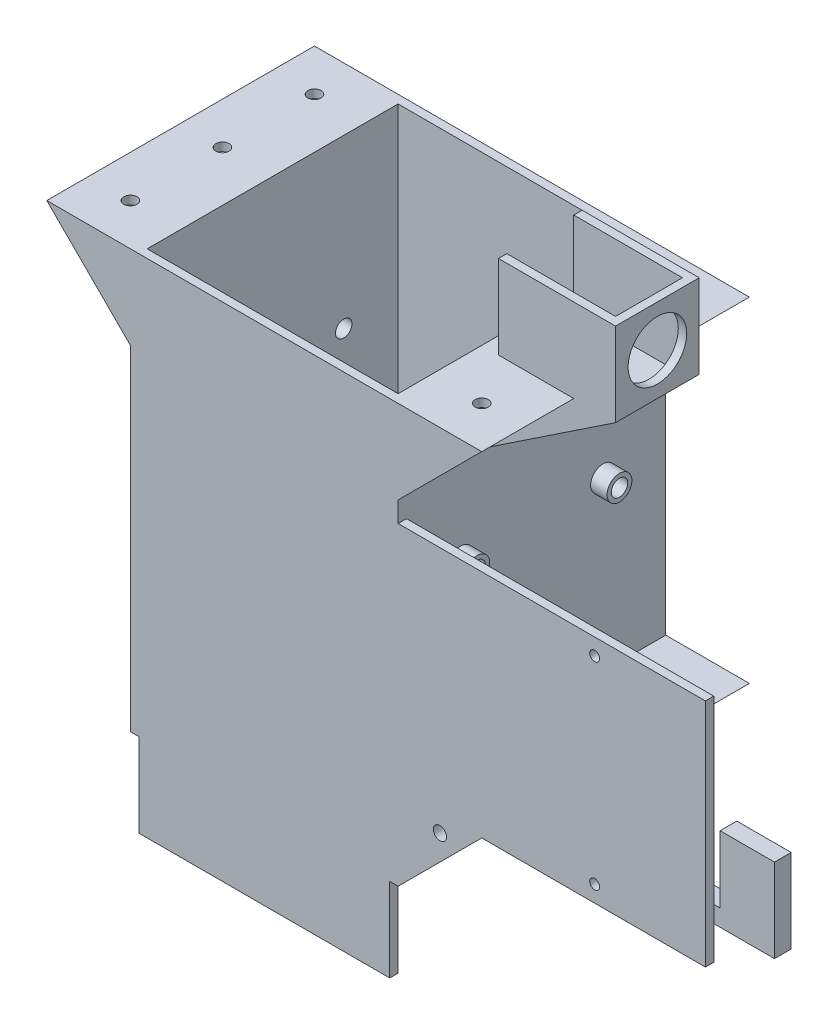
from build123d import *

# Parameters (mm, degrees)
SKETCH1_W            = 81.28
SKETCH1_H            = 81.28
SKETCH1_W_2          = 76.2
SKETCH1_H_2          = 76.2
BOSS_EXTRUDE1_DEPTH  = 177.8
SKETCH2_W            = 2.54
SKETCH2_H            = 38.1
BOSS_EXTRUDE2_DEPTH  = 25.4
SKETCH3_W            = 2.54
SKETCH3_H            = 25.4
CUT_EXTRUDE1_DEPTH   = 212.720846399
BOSS_EXTRUDE3_DEPTH  = 12.7
BOSS_EXTRUDE4_DEPTH  = 12.7
SKETCH14_W           = 5.08
SKETCH14_H           = 25.4
BOSS_EXTRUDE6_DEPTH  = 76.2
CUT_EXTRUDE2_REACH   = 243.407
SKETCH16_W           = 24.13
SKETCH16_H           = 20.32
SKETCH22_R           = 2
CUT_EXTRUDE6_DEPTH   = 252.036309724
SKETCH28_W           = 25.4
SKETCH28_H           = 50.8
BOSS_EXTRUDE7_DEPTH  = 38.1
CUT_EXTRUDE8_REACH   = 245.43
SKETCH32_W           = 33.02
SKETCH32_H           = 20.32
CUT_EXTRUDE9_DEPTH   = 25.4
CUT_EXTRUDE13_REACH  = 245.27
SKETCH34_R           = 8.89
BOSS_EXTRUDE9_DEPTH  = 2.54
SKETCH38_W           = 2.54
SKETCH38_H           = 25.4
CUT_EXTRUDE15_DEPTH  = 63.5
CUT_EXTRUDE17_REACH  = 224.71
SKETCH40_R           = 2.5
SKETCH41_R           = 3.77
SKETCH41_R_2         = 2.5
BOSS_EXTRUDE10_DEPTH = 5
SKETCH42_R           = 3.77
SKETCH42_R_2         = 2.5
BOSS_EXTRUDE11_DEPTH = 5
SKETCH43_W           = 76.2
SKETCH43_H           = 76.2
CUT_EXTRUDE20_DEPTH  = 25.4
SKETCH44_W           = 174.6
SKETCH44_H           = 70
SKETCH44_R           = 1.5
BOSS_EXTRUDE12_DEPTH = 2.54
BOSS_EXTRUDE13_DEPTH = 2.54
BOSS_EXTRUDE14_DEPTH = 2.54
BOSS_EXTRUDE15_REACH = 264.115
BOSS_EXTRUDE16_DEPTH = 2.54
BOSS_EXTRUDE17_DEPTH = 2.54
BOSS_EXTRUDE18_REACH = 264.115
SKETCH51_R           = 2
CUT_EXTRUDE21_DEPTH  = 2.54


with BuildPart() as part:
    # Sketch1 → Boss-Extrude1 (new body)
    with BuildSketch(Plane(origin=(0, 0, 0), x_dir=(1, 0, 0), z_dir=(0, 1, 0))):
        with Locations((40.64, 40.64)):
            Rectangle(SKETCH1_W, SKETCH1_H)
        with Locations((40.64, 40.64)):
            Rectangle(SKETCH1_W_2, SKETCH1_H_2, mode=Mode.SUBTRACT)
    extrude(amount=BOSS_EXTRUDE1_DEPTH)

    # Sketch2 → Boss-Extrude2 (add)
    with BuildSketch(Plane(origin=(0, 0, 0), x_dir=(0, 0, -1), z_dir=(1, 0, 0))):
        with Locations((64.77, 19.05)):
            Rectangle(SKETCH2_W, SKETCH2_H)
    extrude(amount=-BOSS_EXTRUDE2_DEPTH)

    # Sketch3 → Cut-Extrude1 (cut, through all)
    with BuildSketch(Plane.XY):
        with Locations((80.01, 12.7)):
            Rectangle(SKETCH3_W, SKETCH3_H)
    extrude(amount=-CUT_EXTRUDE1_DEPTH, mode=Mode.SUBTRACT)

    # Sketch7 → Boss-Extrude3 (add)
    with BuildSketch(Plane.XY):
        Polygon((81.28, 25.4), (106.68, 50.8), (81.28, 50.8), align=None)
    extrude(amount=-BOSS_EXTRUDE3_DEPTH)

    # Sketch10 → Boss-Extrude4 (add)
    with BuildSketch(Plane(origin=(0, 0, -81.28), x_dir=(-1, 0, 0), z_dir=(0, 0, -1))):
        Polygon((-81.28, 25.4), (-81.28, 50.8), (-106.68, 50.8), align=None)
    extrude(amount=-BOSS_EXTRUDE4_DEPTH)

    # Sketch14 → Boss-Extrude6 (add)
    with BuildSketch(Plane(origin=(81.28, 0, 0), x_dir=(0, 0, -1), z_dir=(1, 0, 0))):
        with Locations((40.64, 38.1)):
            Rectangle(SKETCH14_W, SKETCH14_H)
    extrude(amount=BOSS_EXTRUDE6_DEPTH)

    # Sketch16 → Cut-Extrude2 (cut, up to next)
    with BuildSketch(Plane.XY.offset(-38.1), mode=Mode.PRIVATE) as cut_extrude2_sk1:
        with Locations((128.905, 40.64)):
            Rectangle(SKETCH16_W, SKETCH16_H)
    cut_extrude2_tool1 = extrude(cut_extrude2_sk1.sketch, amount=-CUT_EXTRUDE2_REACH, mode=Mode.PRIVATE) & part.part
    add(cut_extrude2_tool1.solids().sort_by_distance((128.905, 40.64, -38.1))[0], mode=Mode.SUBTRACT)

    # Sketch22 → Cut-Extrude6 (cut, through all)
    with BuildSketch(Plane.XY):
        with Locations((93.98, 45.72)):
            Circle(SKETCH22_R)
    extrude(amount=-CUT_EXTRUDE6_DEPTH, mode=Mode.SUBTRACT)

    # Sketch28 → Boss-Extrude7 (add)
    with BuildSketch(Plane(origin=(81.28, 0, 0), x_dir=(0, 0, -1), z_dir=(1, 0, 0))):
        with Locations((40.64, 152.4)):
            Rectangle(SKETCH28_W, SKETCH28_H)
    extrude(amount=BOSS_EXTRUDE7_DEPTH)

    # Sketch30 → Cut-Extrude8 (cut, up to next)
    with BuildSketch(Plane.XY.offset(-27.94), mode=Mode.PRIVATE) as cut_extrude8_sk1:
        Polygon((81.28, 127), (119.38, 127), (119.38, 152.4), align=None)
    cut_extrude8_tool1 = extrude(cut_extrude8_sk1.sketch, amount=-CUT_EXTRUDE8_REACH, mode=Mode.PRIVATE) & part.part
    add(cut_extrude8_tool1.solids().sort_by_distance((106.68, 135.466667, -27.94))[0], mode=Mode.SUBTRACT)

    # Sketch32 → Cut-Extrude9 (cut)
    with BuildSketch(Plane(origin=(0, 177.8, 0), x_dir=(1, 0, 0), z_dir=(0, 1, 0))):
        with Locations((100.33, 40.64)):
            Rectangle(SKETCH32_W, SKETCH32_H)
    extrude(amount=-CUT_EXTRUDE9_DEPTH, mode=Mode.SUBTRACT)

    # Cut-Extrude13: up to this face of the body (flat: up to its plane)
    cut_extrude13_end = Plane(part.part.faces().sort_by_distance((78.74, 101.6, -40.64))[0])
    # Sketch34 → Cut-Extrude13 (cut, up to the picked face)
    with BuildSketch(Plane(origin=(119.38, 0, 0), x_dir=(0, 0, -1), z_dir=(1, 0, 0)), mode=Mode.PRIVATE) as cut_extrude13_sk1:
        with Locations(Location((40.64, 165.1, 0), (0, 0, 180))):
            Circle(SKETCH34_R)
    cut_extrude13_tool1 = split(extrude(cut_extrude13_sk1.sketch, amount=-CUT_EXTRUDE13_REACH, mode=Mode.PRIVATE), bisect_by=cut_extrude13_end, keep=Keep.BOTH, mode=Mode.PRIVATE)
    add(cut_extrude13_tool1.solids().sort_by(Axis((119.38, 165.1, -40.64), (-1, 0, 0)))[0], mode=Mode.SUBTRACT)

    # Sketch37 → Boss-Extrude9 (add)
    with BuildSketch(Plane.XY.offset(-63.5)):
        Polygon((-25.4, 38.1), (0, 38.1), (0, 52.764696837), align=None)
    extrude(amount=-BOSS_EXTRUDE9_DEPTH)

    # Sketch38 → Cut-Extrude15 (cut)
    with BuildSketch(Plane.XY):
        with Locations((1.27, 12.7)):
            Rectangle(SKETCH38_W, SKETCH38_H)
    extrude(amount=-CUT_EXTRUDE15_DEPTH, mode=Mode.SUBTRACT)

    # Cut-Extrude17: up to this face of the body (flat: up to its plane)
    cut_extrude17_end = Plane(part.part.faces().sort_by_distance((0, 99.23335202, -41.514066738))[0])
    # Sketch40 → Cut-Extrude17 (cut, up to the picked face)
    with BuildSketch(Plane(origin=(81.28, 0, 0), x_dir=(0, 0, -1), z_dir=(1, 0, 0)), mode=Mode.PRIVATE) as cut_extrude17_sk1:
        with Locations((19.05, 101.6)):
            Circle(SKETCH40_R)
    cut_extrude17_tool1 = split(extrude(cut_extrude17_sk1.sketch, amount=-CUT_EXTRUDE17_REACH, mode=Mode.PRIVATE), bisect_by=cut_extrude17_end, keep=Keep.BOTH, mode=Mode.PRIVATE)
    # Sketch40 → Cut-Extrude17 (cut, up to the picked face)
    with BuildSketch(Plane(origin=(81.28, 0, 0), x_dir=(0, 0, -1), z_dir=(1, 0, 0)), mode=Mode.PRIVATE) as cut_extrude17_sk2:
        with Locations((62.23, 101.6)):
            Circle(SKETCH40_R)
    cut_extrude17_tool2 = split(extrude(cut_extrude17_sk2.sketch, amount=-CUT_EXTRUDE17_REACH, mode=Mode.PRIVATE), bisect_by=cut_extrude17_end, keep=Keep.BOTH, mode=Mode.PRIVATE)
    add(cut_extrude17_tool1.solids().sort_by(Axis((81.28, 101.6, -19.05), (-1, 0, 0)))[0], mode=Mode.SUBTRACT)
    add(cut_extrude17_tool2.solids().sort_by(Axis((81.28, 101.6, -62.23), (-1, 0, 0)))[0], mode=Mode.SUBTRACT)

    # Sketch41 → Boss-Extrude10 (add)
    with BuildSketch(Plane(origin=(81.28, 0, 0), x_dir=(0, 0, -1), z_dir=(1, 0, 0))):
        with Locations(Location((19.05, 101.6, 0), (0, 0, 180))):
            Circle(SKETCH41_R)
        with Locations((19.05, 101.6)):
            Circle(SKETCH41_R_2, mode=Mode.SUBTRACT)
        with Locations(Location((62.23, 101.6, 0), (0, 0, 180))):
            Circle(SKETCH41_R)
        with Locations((62.23, 101.6)):
            Circle(SKETCH41_R_2, mode=Mode.SUBTRACT)
    extrude(amount=BOSS_EXTRUDE10_DEPTH)

    # Sketch42 → Boss-Extrude11 (add)
    with BuildSketch(Plane.ZY):
        with Locations((-62.23, 101.6)):
            Circle(SKETCH42_R)
        with Locations(Location((-62.23, 101.6, 0), (0, 0, 180))):
            Circle(SKETCH42_R_2, mode=Mode.SUBTRACT)
        with Locations((-19.05, 101.6)):
            Circle(SKETCH42_R)
        with Locations(Location((-19.05, 101.6, 0), (0, 0, 180))):
            Circle(SKETCH42_R_2, mode=Mode.SUBTRACT)
    extrude(amount=BOSS_EXTRUDE11_DEPTH)

    # Sketch43 → Cut-Extrude20 (cut)
    with BuildSketch(Plane(origin=(0, 177.8, 0), x_dir=(1, 0, 0), z_dir=(0, 1, 0))):
        Polygon((83.82, 53.34), (83.82, 27.94), (81.28, 27.94), (81.28, 0), (0, 0), (0, 81.28), (81.28, 81.28), (81.28, 53.34), align=None)
        with Locations((40.64, 40.64)):
            Rectangle(SKETCH43_W, SKETCH43_H, mode=Mode.SUBTRACT)
    extrude(amount=-CUT_EXTRUDE20_DEPTH, mode=Mode.SUBTRACT)

    # Sketch44 → Boss-Extrude12 (add)
    with BuildSketch(Plane.XY):
        with Locations((87.3, 85.8)):
            Rectangle(SKETCH44_W, SKETCH44_H)
        with Locations((140.97, 115.8)):
            Circle(SKETCH44_R, mode=Mode.SUBTRACT)
        with Locations((140.97, 55.8)):
            Circle(SKETCH44_R, mode=Mode.SUBTRACT)
    extrude(amount=-BOSS_EXTRUDE12_DEPTH)

    # Sketch45 → Boss-Extrude13 (add)
    with BuildSketch(Plane.XY):
        Polygon((0, 152.4), (-25.4, 152.4), (0, 127), align=None)
    extrude(amount=-BOSS_EXTRUDE13_DEPTH)

    # Sketch46 → Boss-Extrude14 (add)
    with BuildSketch(Plane(origin=(0, 0, -81.28), x_dir=(-1, 0, 0), z_dir=(0, 0, -1))):
        Polygon((0, 152.4), (0, 127), (25.4, 152.4), align=None)
    extrude(amount=-BOSS_EXTRUDE14_DEPTH)

    # Sketch47 → Boss-Extrude15 (add, up to next)
    with BuildSketch(Plane.XY, mode=Mode.PRIVATE) as boss_extrude15_sk1:
        Polygon((0, 152.4), (-25.4, 152.4), (-22.86, 149.86), (0, 149.86), align=None)
    boss_extrude15_tool1 = extrude(boss_extrude15_sk1.sketch, amount=-BOSS_EXTRUDE15_REACH, mode=Mode.PRIVATE) - part.part
    add(boss_extrude15_tool1.solids().sort_by_distance((-12.07614, 151.152281, 0))[0])

    # Sketch48 → Boss-Extrude16 (add)
    with BuildSketch(Plane.XY):
        Polygon((81.28, 152.4), (106.68, 152.4), (81.28, 127), align=None)
    extrude(amount=-BOSS_EXTRUDE16_DEPTH)

    # Sketch49 → Boss-Extrude17 (add)
    with BuildSketch(Plane(origin=(0, 0, -81.28), x_dir=(-1, 0, 0), z_dir=(0, 0, -1))):
        Polygon((-81.28, 152.4), (-106.68, 152.4), (-81.28, 127), align=None)
    extrude(amount=-BOSS_EXTRUDE17_DEPTH)

    # Sketch50 → Boss-Extrude18 (add, up to next)
    with BuildSketch(Plane(origin=(0, 0, -81.28), x_dir=(-1, 0, 0), z_dir=(0, 0, -1)), mode=Mode.PRIVATE) as boss_extrude18_sk1:
        Polygon((-81.28, 152.4), (-106.68, 152.4), (-104.14, 149.86), (-81.28, 149.86), align=None)
    boss_extrude18_tool1 = extrude(boss_extrude18_sk1.sketch, amount=-BOSS_EXTRUDE18_REACH, mode=Mode.PRIVATE) - part.part
    add(boss_extrude18_tool1.solids().sort_by_distance((93.35614, 151.152281, -81.28))[0])
    add(boss_extrude18_tool1.solids().sort_by_distance((93.35614, 151.152281, -81.28))[1])

    # Sketch51 → Cut-Extrude21 (cut)
    with BuildSketch(Plane(origin=(0, 152.4, 0), x_dir=(1, 0, 0), z_dir=(0, 1, 0))):
        with Locations(Location((-12.7, 68.58, 0), (0, 0, 270))):
            Circle(SKETCH51_R)
        with Locations(Location((-12.7, 40.64, 0), (0, 0, 270))):
            Circle(SKETCH51_R)
        with Locations(Location((-12.7, 12.7, 0), (0, 0, 270))):
            Circle(SKETCH51_R)
        with Locations(Location((93.98, 68.58, 0), (0, 0, 270))):
            Circle(SKETCH51_R)
        with Locations(Location((93.98, 12.7, 0), (0, 0, 270))):
            Circle(SKETCH51_R)
    extrude(amount=-CUT_EXTRUDE21_DEPTH, mode=Mode.SUBTRACT)


solid = part.part
